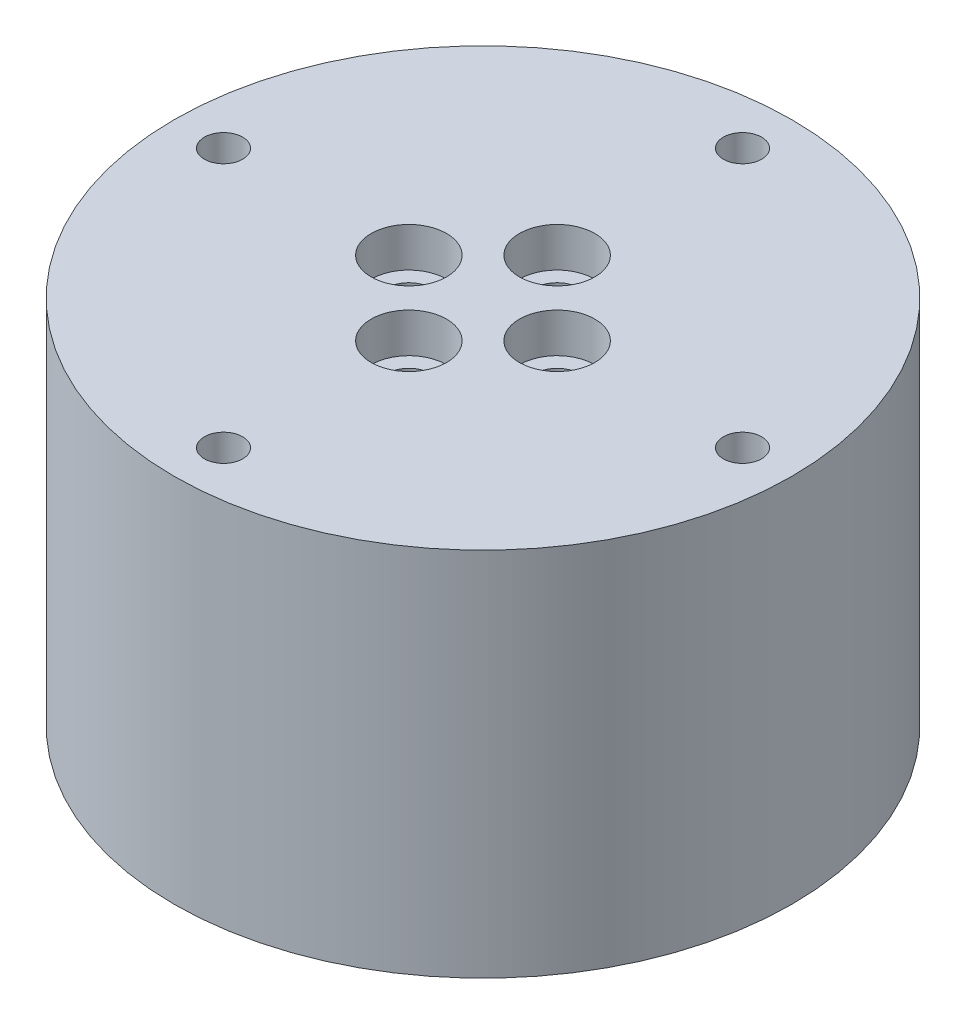
from build123d import *

# Parameters (mm, degrees)
SKETCH1_R           = 25
BOSS_EXTRUDE1_DEPTH = 5
SKETCH2_R           = 25
SKETCH2_R_2         = 15.5
BOSS_EXTRUDE2_DEPTH = 25
SKETCH3_R           = 3.05
SKETCH3_R_2         = 1.8
CUT_EXTRUDE1_DEPTH  = 3.2
CUT_EXTRUDE2_REACH  = 48.368
SKETCH3_2_R         = 1.8
SKETCH4_R           = 1.55
CUT_EXTRUDE4_DEPTH  = 7
CIRPATTERN1_COUNT   = 4
FILLET1_R           = 9
FILLET2_R           = 2


with BuildPart() as part:
    # Sketch1 → Boss-Extrude1 (new body)
    with BuildSketch(Plane(origin=(0, 0, 0), x_dir=(1, 0, 0), z_dir=(0, 1, 0))):
        Circle(SKETCH1_R)
    extrude(amount=-BOSS_EXTRUDE1_DEPTH)

    # Sketch2 → Boss-Extrude2 (add)
    with BuildSketch(Plane.XZ.offset(5)):
        Circle(SKETCH2_R)
        Circle(SKETCH2_R_2, mode=Mode.SUBTRACT)
    extrude(amount=BOSS_EXTRUDE2_DEPTH)

    # Sketch3 → Cut-Extrude1 (cut)
    with BuildSketch(Plane(origin=(0, 0, 0), x_dir=(1, 0, 0), z_dir=(0, 1, 0))):
        with Locations((0, 6)):
            Circle(SKETCH3_R)
        with Locations((0, 6)):
            Circle(SKETCH3_R_2, mode=Mode.SUBTRACT)
    cut_extrude1 = extrude(amount=-CUT_EXTRUDE1_DEPTH, mode=Mode.SUBTRACT)

    # Sketch3_2 → Cut-Extrude2 (cut, up to next)
    with BuildSketch(Plane(origin=(0, 0, 0), x_dir=(1, 0, 0), z_dir=(0, 1, 0)), mode=Mode.PRIVATE) as cut_extrude2_sk1:
        with Locations((0, 6)):
            Circle(SKETCH3_2_R)
    cut_extrude2_tool1 = extrude(cut_extrude2_sk1.sketch, amount=-CUT_EXTRUDE2_REACH, mode=Mode.PRIVATE) & part.part
    cut_extrude2 = cut_extrude2_tool1.solids().sort_by_distance((0, 0, -6))[0]
    add(cut_extrude2, mode=Mode.SUBTRACT)

    # Sketch4 → Cut-Extrude4 (cut)
    with BuildSketch(Plane(origin=(0, 0, 0), x_dir=(1, 0, 0), z_dir=(0, 1, 0))):
        with Locations((0, 21)):
            Circle(SKETCH4_R)
    cut_extrude4 = extrude(amount=-CUT_EXTRUDE4_DEPTH, mode=Mode.SUBTRACT)

    # CirPattern1: Cut-Extrude1, Cut-Extrude2, Cut-Extrude4 ×4 about axis
    cirpattern1_axis = Axis((0, -5, 0), (0, 1, 0))
    add([cut_extrude1.rotate(cirpattern1_axis, i * 360 / CIRPATTERN1_COUNT) for i in range(1, CIRPATTERN1_COUNT)], mode=Mode.SUBTRACT)
    add([cut_extrude2.rotate(cirpattern1_axis, i * 360 / CIRPATTERN1_COUNT) for i in range(1, CIRPATTERN1_COUNT)], mode=Mode.SUBTRACT)
    add([cut_extrude4.rotate(cirpattern1_axis, i * 360 / CIRPATTERN1_COUNT) for i in range(1, CIRPATTERN1_COUNT)], mode=Mode.SUBTRACT)

    # Fillet1
    fillet1_edges = [part.edges().sort_by_distance(p)[0] for p in [
        (-15.5, -30, 0),
    ]]
    fillet(fillet1_edges, radius=FILLET1_R)

    # Fillet2
    fillet2_edges = [part.edges().sort_by_distance(p)[0] for p in [
        (-15.5, -5, 0),
    ]]
    fillet(fillet2_edges, radius=FILLET2_R)


solid = part.part
